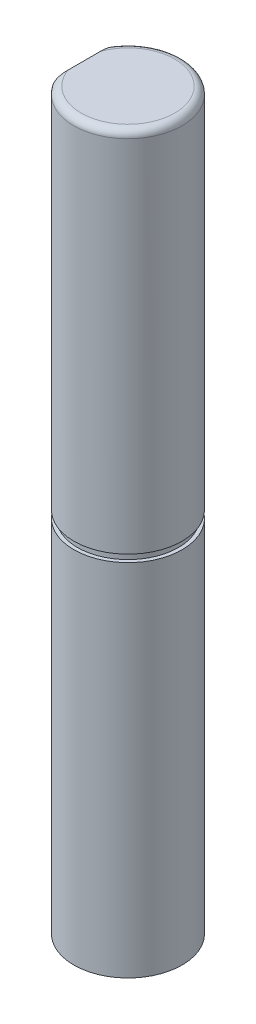
from build123d import *

# Parameters (mm, degrees)
SKETCH_1_R          = 1.475
EXTRUDE_1_DEPTH     = 20
SKETCH_2_R          = 1.475
SKETCH_2_R_2        = 1.375
CUT_EXTRUDE_4_DEPTH = 0.2
CUT_EXTRUDE_1_DEPTH = 7.42
FILLET_1_R          = 0.2


with BuildPart() as part:
    # 草图1 → 凸台-拉伸1 (new body)
    with BuildSketch(Plane(origin=(0, 0, 0), x_dir=(1, 0, 0), z_dir=(0, 1, 0))):
        Circle(SKETCH_1_R)
    extrude(amount=EXTRUDE_1_DEPTH)

    # 草图2 → 切除-拉伸-薄壁4 (cut)
    with BuildSketch(Plane(origin=(0, 10, 0), x_dir=(1, 0, 0), z_dir=(0, 1, 0))):
        Circle(SKETCH_2_R)
        Circle(SKETCH_2_R_2, mode=Mode.SUBTRACT)
    extrude(amount=-CUT_EXTRUDE_4_DEPTH, mode=Mode.SUBTRACT)

    # 草图3 → 切除-拉伸1 (cut)
    with BuildSketch(Plane(origin=(0, 20, 0), x_dir=(1, 0, 0), z_dir=(0, 1, 0))):
        with BuildLine():
            Line((-1.195, 0.864638653), (-1.195, -0.864638653))
            ThreePointArc((-1.195, -0.864638653), (-1.475, 0), (-1.195, 0.864638653))
        make_face()
    extrude(amount=-CUT_EXTRUDE_1_DEPTH, mode=Mode.SUBTRACT)

    # 圆角1
    fillet_1_edges = [part.edges().sort_by_distance(p)[0] for p in [
        (0.454422711, 20, 1.403255144),
    ]]
    fillet(fillet_1_edges, radius=FILLET_1_R)


solid = part.part
